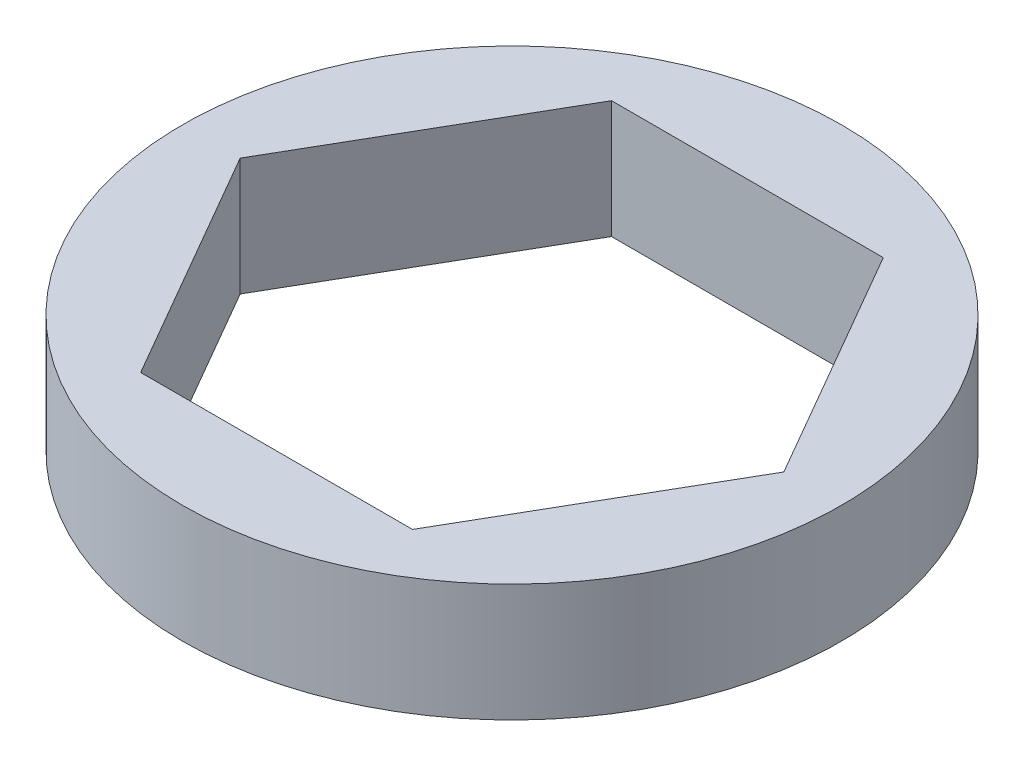
from build123d import *

# Parameters (mm, degrees)
SKETCH1_R           = 8.89
BOSS_EXTRUDE1_DEPTH = 3.175


with BuildPart() as part:
    # Sketch1 → Boss-Extrude1 (new body)
    with BuildSketch(Plane(origin=(0, 0, 0), x_dir=(1, 0, 0), z_dir=(0, 1, 0))):
        Circle(SKETCH1_R)
        Polygon((7.332348419, 0), (3.666174209, 6.35), (-3.666174209, 6.35), (-7.332348419, 0), (-3.666174209, -6.35), (3.666174209, -6.35), align=None, mode=Mode.SUBTRACT)
    extrude(amount=BOSS_EXTRUDE1_DEPTH)


solid = part.part
